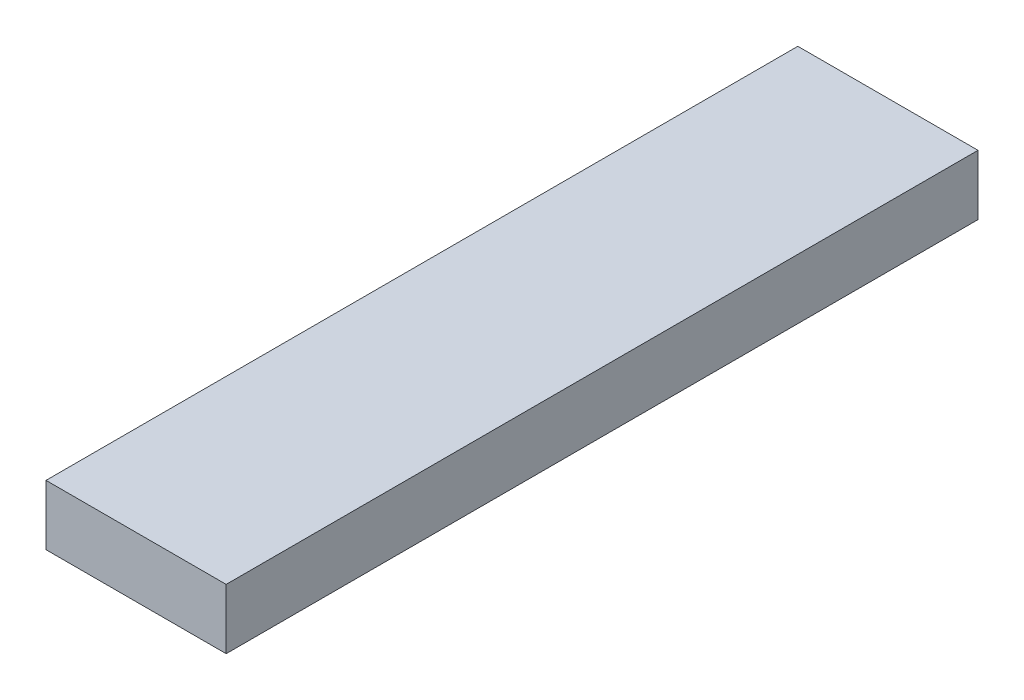
from build123d import *

# Parameters (mm, degrees)
SKETCH1_W           = 38.1
SKETCH1_H           = 12.7
BOSS_EXTRUDE1_DEPTH = 159


with BuildPart() as part:
    # Sketch1 → Boss-Extrude1 (new body)
    with BuildSketch(Plane.XY):
        with Locations((19.05, 6.35)):
            Rectangle(SKETCH1_W, SKETCH1_H)
    extrude(amount=BOSS_EXTRUDE1_DEPTH)


solid = part.part
